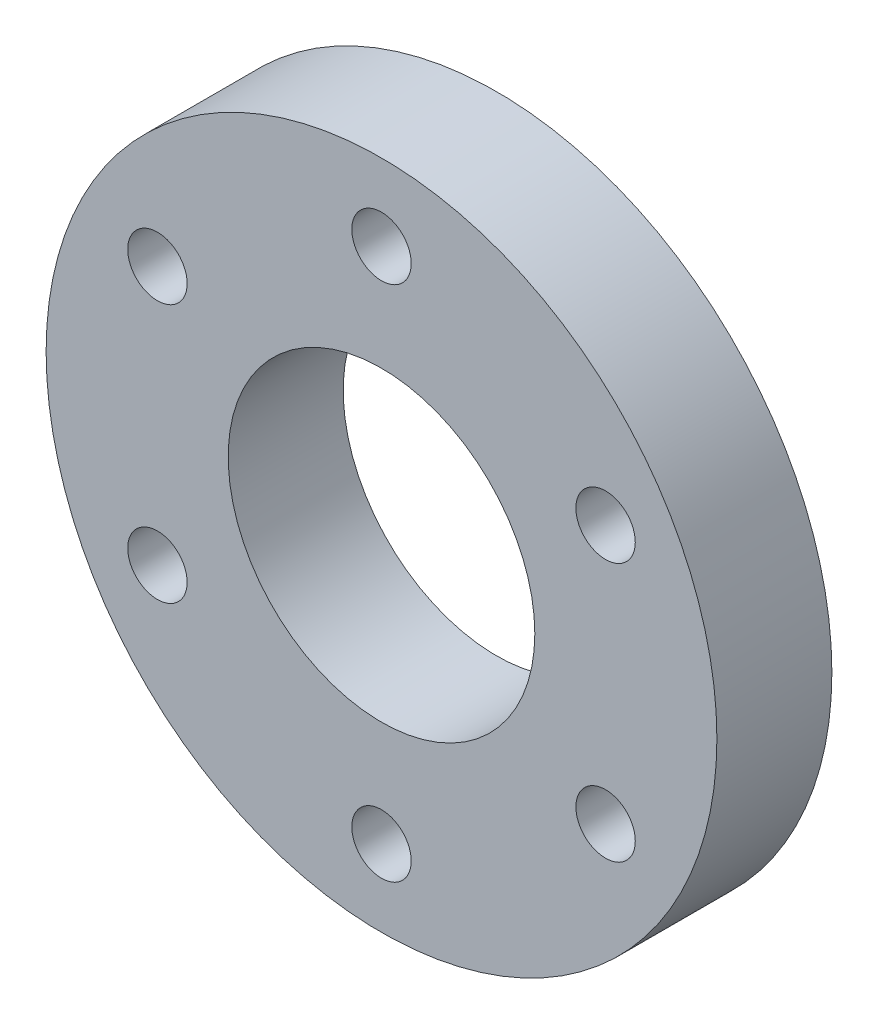
from build123d import *

# Parameters (mm, degrees)
SKETCH_1_R      = 17.5
SKETCH_1_R_2    = 8
SKETCH_1_R_3    = 1.55
EXTRUDE_1_DEPTH = 6


with BuildPart() as part:
    # 草图1 → 凸台-拉伸1 (new body)
    with BuildSketch(Plane.XY):
        Circle(SKETCH_1_R)
        Circle(SKETCH_1_R_2, mode=Mode.SUBTRACT)
        with Locations((0, 13.5)):
            Circle(SKETCH_1_R_3, mode=Mode.SUBTRACT)
        with Locations((11.691342951, -6.75)):
            Circle(SKETCH_1_R_3, mode=Mode.SUBTRACT)
        with Locations((-11.691342951, 6.75)):
            Circle(SKETCH_1_R_3, mode=Mode.SUBTRACT)
        with Locations((-11.691342951, -6.75)):
            Circle(SKETCH_1_R_3, mode=Mode.SUBTRACT)
        with Locations((11.691342951, 6.75)):
            Circle(SKETCH_1_R_3, mode=Mode.SUBTRACT)
        with Locations((0, -13.5)):
            Circle(SKETCH_1_R_3, mode=Mode.SUBTRACT)
    extrude(amount=EXTRUDE_1_DEPTH)


solid = part.part
